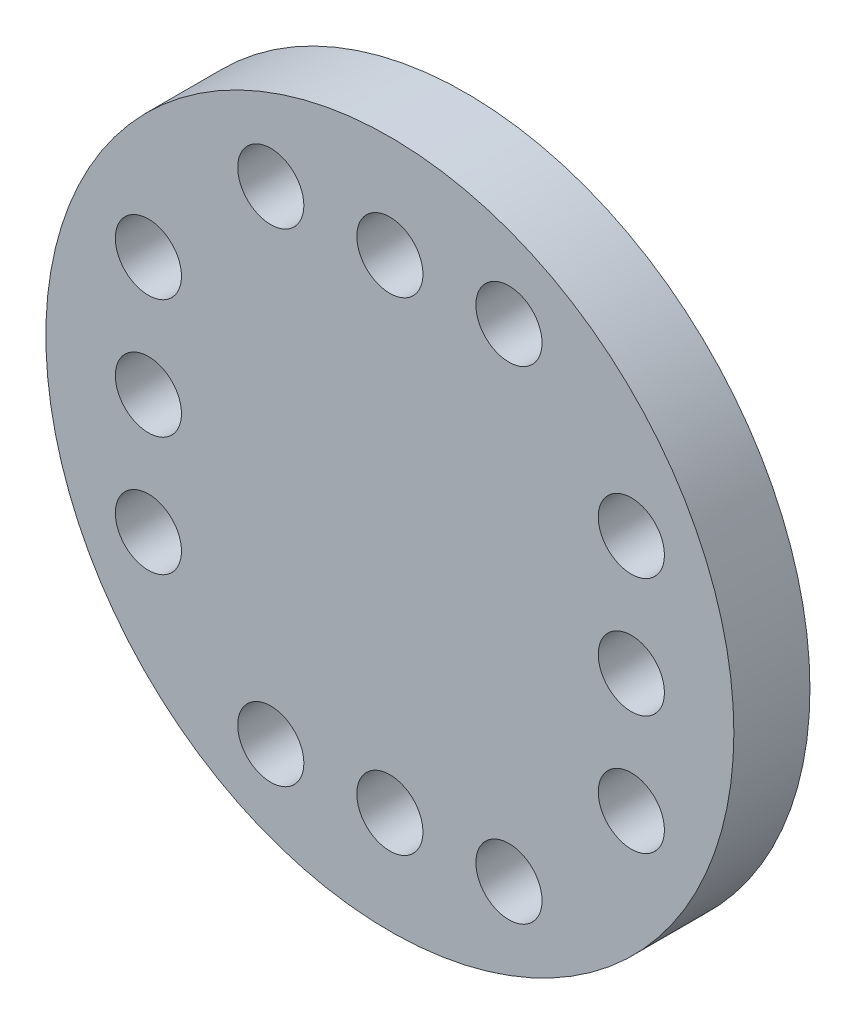
from build123d import *

# Parameters (mm, degrees)
EXTRUDE_START       = 1
SKETCH_2_R          = 4.4
SKETCH_2_R_2        = 2.95
EXTRUDE_2_DEPTH     = 3
SKETCH_3_R          = 10.4
EXTRUDE_3_DEPTH     = 2.3
SKETCH_5_R          = 1
CUT_EXTRUDE_1_DEPTH = 2.3


with BuildPart() as part:
    # 스케치2 → 보스-돌출2 (new body)
    with BuildSketch(Plane.XY.offset(-4).offset(EXTRUDE_START)):
        with Locations((10.45, 0)):
            Circle(SKETCH_2_R)
        with Locations((10.45, 0)):
            Circle(SKETCH_2_R_2, mode=Mode.SUBTRACT)
    extrude(amount=EXTRUDE_2_DEPTH)

    # 스케치3 → 보스-돌출3 (add)
    with BuildSketch(Plane.XY):
        with Locations((10.45, 0)):
            Circle(SKETCH_3_R)
    extrude(amount=EXTRUDE_3_DEPTH)

    # 스케치5 → 컷-돌출1 (cut)
    with BuildSketch(Plane.XY.offset(2.3)):
        with Locations((10.45, 7.3)):
            Circle(SKETCH_5_R)
        with Locations((14.05, 7.3)):
            Circle(SKETCH_5_R)
        with Locations((6.85, 7.3)):
            Circle(SKETCH_5_R)
        with Locations((3.15, 0)):
            Circle(SKETCH_5_R)
        with Locations((3.15, 3.6)):
            Circle(SKETCH_5_R)
        with Locations((3.15, -3.6)):
            Circle(SKETCH_5_R)
        with Locations((10.45, -7.3)):
            Circle(SKETCH_5_R)
        with Locations((6.85, -7.3)):
            Circle(SKETCH_5_R)
        with Locations((14.05, -7.3)):
            Circle(SKETCH_5_R)
        with Locations((17.75, 0)):
            Circle(SKETCH_5_R)
        with Locations((17.75, -3.6)):
            Circle(SKETCH_5_R)
        with Locations((17.75, 3.6)):
            Circle(SKETCH_5_R)
    extrude(amount=-CUT_EXTRUDE_1_DEPTH, mode=Mode.SUBTRACT)


solid = part.part
